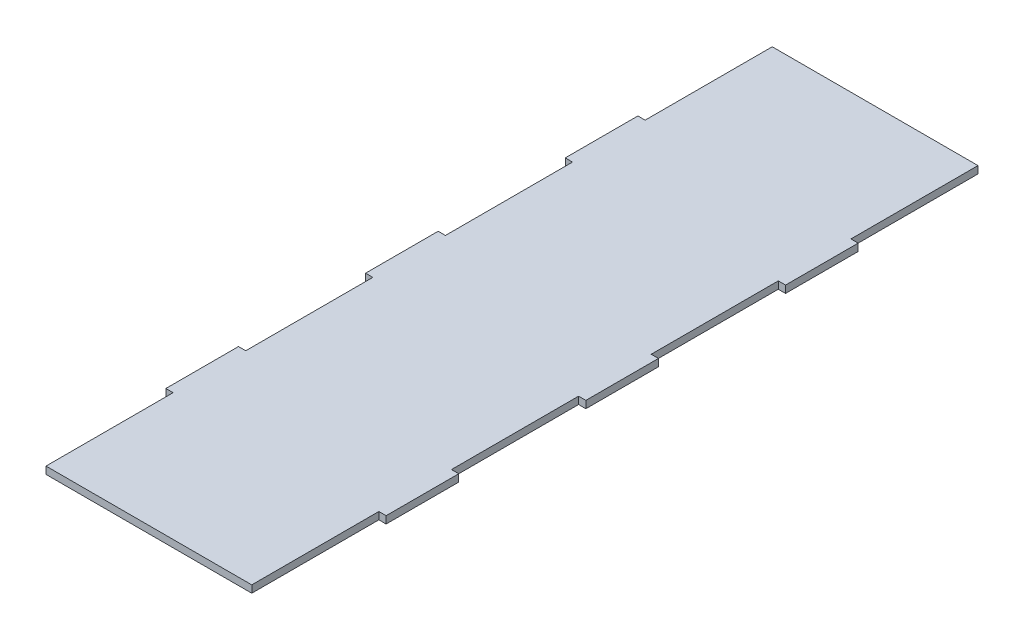
from build123d import *

# Parameters (mm, degrees)
SALIENTE_EXTRUIR1_DEPTH = 3


with BuildPart() as part:
    # Croquis1 → Saliente-Extruir1 (new body)
    with BuildSketch(Plane(origin=(0, 0, 0), x_dir=(1, 0, 0), z_dir=(0, 1, 0))):
        Polygon((-45.5, 67.5), (-42.5, 67.5), (-42.5, 15), (-45.5, 15), (-45.5, -15), (-42.5, -15), (-42.5, -67.5), (-45.5, -67.5), (-45.5, -97.5), (-42.5, -97.5), (-42.5, -150), (42.5, -150), (42.5, -97.5), (45.5, -97.5), (45.5, -67.5), (42.5, -67.5), (42.5, -15), (45.5, -15), (45.5, 15), (42.5, 15), (42.5, 67.5), (45.5, 67.5), (45.5, 97.5), (42.5, 97.5), (42.5, 150), (-42.5, 150), (-42.5, 97.5), (-45.5, 97.5), align=None)
    extrude(amount=SALIENTE_EXTRUIR1_DEPTH)


solid = part.part
